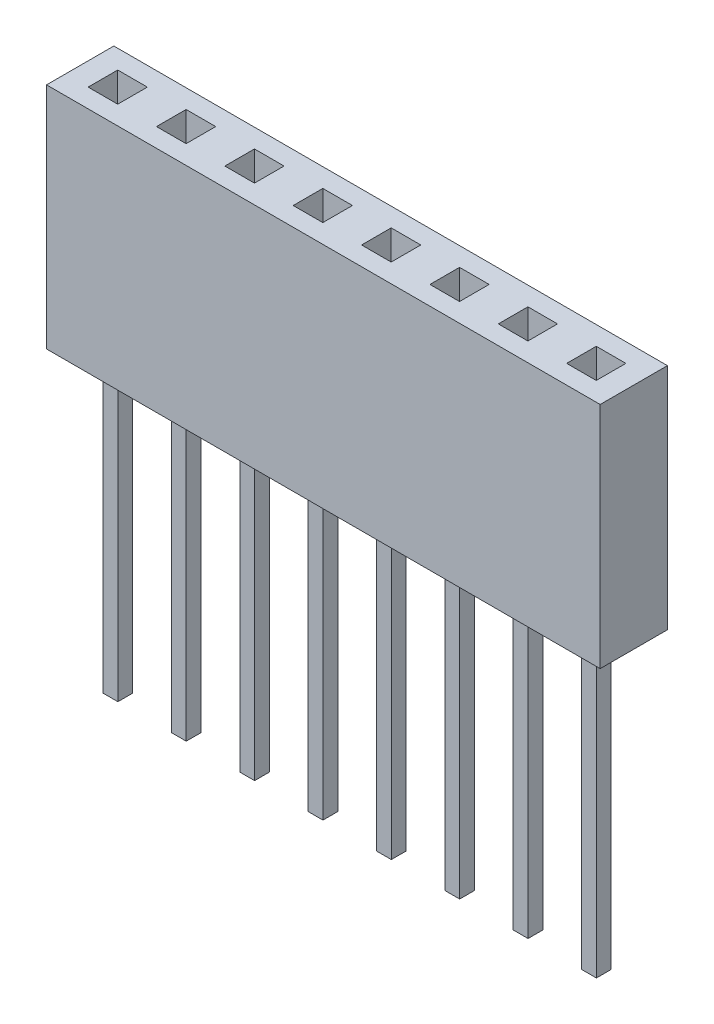
from build123d import *

# Parameters (mm, degrees)
SKETCH1_W             = 20.57
SKETCH1_H             = 8.5
BOSS_EXTRUDE1_DEPTH   = 1.25
SKETCH2_W             = 1.1
SKETCH2_H             = 1.1
CUT_EXTRUDE1_DEPTH    = 23.292092769
SKETCH3_W             = 20.57
SKETCH3_H             = 2.5
BOSS_EXTRUDE2_DEPTH   = 1
SKETCH4_W             = 0.55
SKETCH4_H             = 0.55
BOSS_EXTRUDE3_DEPTH   = 11
BOSS_EXTRUDE3_2_DEPTH = 11
BOSS_EXTRUDE3_3_DEPTH = 11
BOSS_EXTRUDE3_4_DEPTH = 11
BOSS_EXTRUDE3_5_DEPTH = 11
BOSS_EXTRUDE3_6_DEPTH = 11
BOSS_EXTRUDE3_7_DEPTH = 11
BOSS_EXTRUDE3_8_DEPTH = 11


with BuildPart() as part:
    # Sketch1 → Boss-Extrude1 (new, symmetric)
    with BuildSketch(Plane.XY):
        with Locations((10.285, 4.25)):
            Rectangle(SKETCH1_W, SKETCH1_H)
    extrude(amount=BOSS_EXTRUDE1_DEPTH, both=True)

    # Sketch2 → Cut-Extrude1 (cut, through all)
    with BuildSketch(Plane.XZ):
        with Locations((3.935, 0)):
            Rectangle(SKETCH2_W, SKETCH2_H)
        with Locations((1.395, 0)):
            Rectangle(SKETCH2_W, SKETCH2_H)
        with Locations((6.475, 0)):
            Rectangle(SKETCH2_W, SKETCH2_H)
        with Locations((9.015, 0)):
            Rectangle(SKETCH2_W, SKETCH2_H)
        with Locations((11.555, 0)):
            Rectangle(SKETCH2_W, SKETCH2_H)
        with Locations((14.095, 0)):
            Rectangle(SKETCH2_W, SKETCH2_H)
        with Locations((16.635, 0)):
            Rectangle(SKETCH2_W, SKETCH2_H)
        with Locations((19.175, 0)):
            Rectangle(SKETCH2_W, SKETCH2_H)
    extrude(amount=-CUT_EXTRUDE1_DEPTH, mode=Mode.SUBTRACT)

    # Sketch3 → Boss-Extrude2 (add)
    with BuildSketch(Plane.XZ):
        with Locations((10.285, 0)):
            Rectangle(SKETCH3_W, SKETCH3_H)
    extrude(amount=-BOSS_EXTRUDE2_DEPTH)


with BuildPart() as body_2:
    # Sketch4 → Boss-Extrude3 (new body)
    with BuildSketch(Plane.XZ):
        with Locations((1.4, 0)):
            Rectangle(SKETCH4_W, SKETCH4_H)
    extrude(amount=BOSS_EXTRUDE3_DEPTH)


with BuildPart() as body_3:
    # Sketch4 → Boss-Extrude3 2 (new body)
    with BuildSketch(Plane.XZ):
        with Locations((3.94, 0)):
            Rectangle(SKETCH4_W, SKETCH4_H)
    extrude(amount=BOSS_EXTRUDE3_2_DEPTH)


with BuildPart() as body_4:
    # Sketch4 → Boss-Extrude3 3 (new body)
    with BuildSketch(Plane.XZ):
        with Locations((6.48, 0)):
            Rectangle(SKETCH4_W, SKETCH4_H)
    extrude(amount=BOSS_EXTRUDE3_3_DEPTH)


with BuildPart() as body_5:
    # Sketch4 → Boss-Extrude3 4 (new body)
    with BuildSketch(Plane.XZ):
        with Locations((9.02, 0)):
            Rectangle(SKETCH4_W, SKETCH4_H)
    extrude(amount=BOSS_EXTRUDE3_4_DEPTH)


with BuildPart() as body_6:
    # Sketch4 → Boss-Extrude3 5 (new body)
    with BuildSketch(Plane.XZ):
        with Locations((11.56, 0)):
            Rectangle(SKETCH4_W, SKETCH4_H)
    extrude(amount=BOSS_EXTRUDE3_5_DEPTH)


with BuildPart() as body_7:
    # Sketch4 → Boss-Extrude3 6 (new body)
    with BuildSketch(Plane.XZ):
        with Locations((14.1, 0)):
            Rectangle(SKETCH4_W, SKETCH4_H)
    extrude(amount=BOSS_EXTRUDE3_6_DEPTH)


with BuildPart() as body_8:
    # Sketch4 → Boss-Extrude3 7 (new body)
    with BuildSketch(Plane.XZ):
        with Locations((16.64, 0)):
            Rectangle(SKETCH4_W, SKETCH4_H)
    extrude(amount=BOSS_EXTRUDE3_7_DEPTH)


with BuildPart() as body_9:
    # Sketch4 → Boss-Extrude3 8 (new body)
    with BuildSketch(Plane.XZ):
        with Locations((19.18, 0)):
            Rectangle(SKETCH4_W, SKETCH4_H)
    extrude(amount=BOSS_EXTRUDE3_8_DEPTH)


solid = Compound([part.part, body_2.part, body_3.part, body_4.part, body_5.part, body_6.part, body_7.part, body_8.part, body_9.part])
